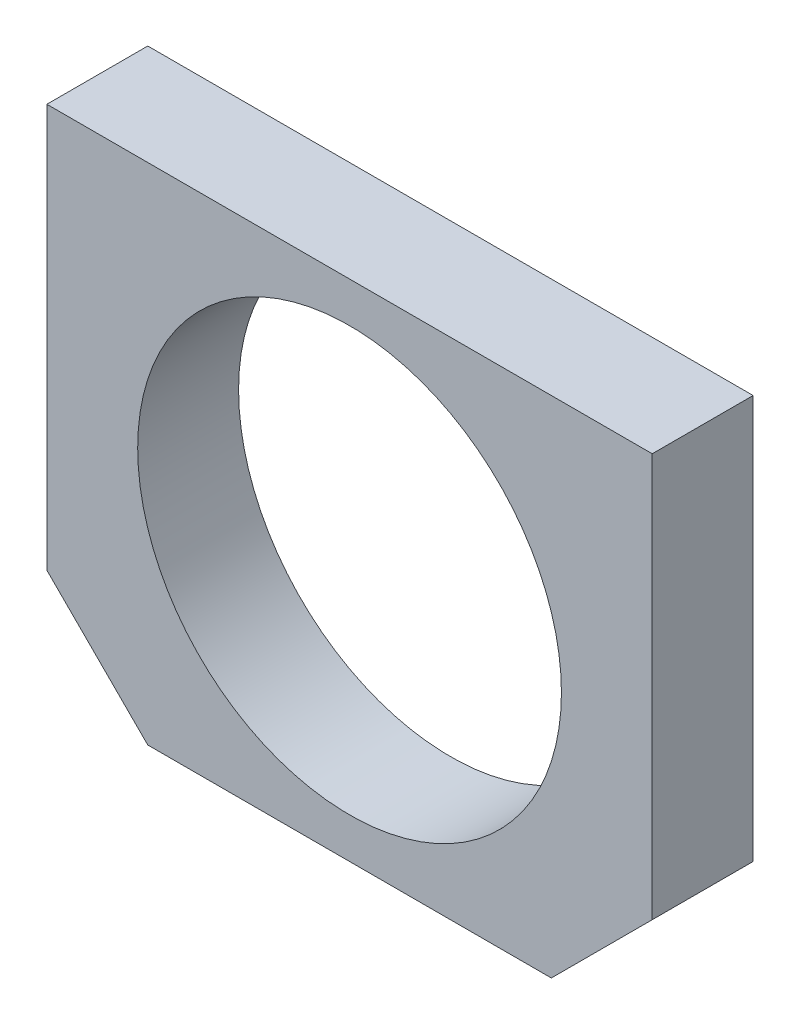
from build123d import *

# Parameters (mm, degrees)
CROQUIS1_R              = 21
SALIENTE_EXTRUIR1_DEPTH = 10


with BuildPart() as part:
    # Croquis1 → Saliente-Extruir1 (new body)
    with BuildSketch(Plane.XY):
        Polygon((-30, 25), (-30, -15), (-20, -25), (20, -25), (30, -15), (30, 25), align=None)
        Circle(CROQUIS1_R, mode=Mode.SUBTRACT)
    extrude(amount=SALIENTE_EXTRUIR1_DEPTH)


solid = part.part
